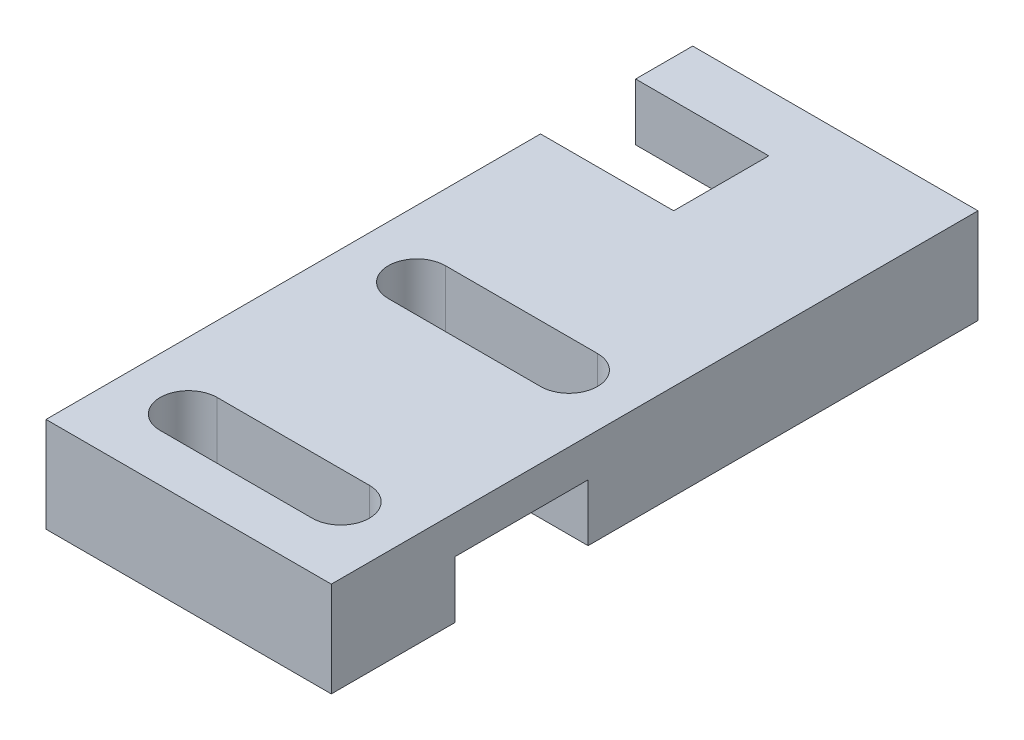
from build123d import *

# Parameters (mm, degrees)
EXTRUDE_1_DEPTH     = 5
SKETCH_2_W          = 7
SKETCH_2_H          = 3
CUT_EXTRUDE_1_DEPTH = 16
SKETCH_3_W          = 3
SKETCH_3_H          = 2
CUT_EXTRUDE_2_DEPTH = 12


with BuildPart() as part:
    # 草图1 → 凸台-拉伸1 (new body)
    with BuildSketch(Plane(origin=(0, 0, 0), x_dir=(1, 0, 0), z_dir=(0, 1, 0))):
        Polygon((15, 34), (0, 34), (0, 31), (7, 31), (7, 26), (0, 26), (0, 0), (15, 0), align=None)
        with BuildLine():
            ThreePointArc((3.5, 2.5), (2, 4), (3.5, 5.5))
            Line((3.5, 5.5), (11.5, 5.5))
            ThreePointArc((11.5, 5.5), (13, 4), (11.5, 2.5))
            Line((11.5, 2.5), (3.5, 2.5))
        make_face(mode=Mode.SUBTRACT)
        with BuildLine():
            ThreePointArc((3.5, 14.5), (2, 16), (3.5, 17.5))
            Line((3.5, 17.5), (11.5, 17.5))
            ThreePointArc((11.5, 17.5), (13, 16), (11.5, 14.5))
            Line((11.5, 14.5), (3.5, 14.5))
        make_face(mode=Mode.SUBTRACT)
    extrude(amount=EXTRUDE_1_DEPTH)

    # 草图2 → 切除-拉伸1 (cut, through all)
    with BuildSketch(Plane.ZY):
        with Locations((-10, 1.5)):
            Rectangle(SKETCH_2_W, SKETCH_2_H)
    extrude(amount=-CUT_EXTRUDE_1_DEPTH, mode=Mode.SUBTRACT)

    # 草图3 → 切除-拉伸2 (cut)
    with BuildSketch(Plane.ZY.offset(-7)):
        with Locations((-32.5, 1)):
            Rectangle(SKETCH_3_W, SKETCH_3_H)
    extrude(amount=CUT_EXTRUDE_2_DEPTH, mode=Mode.SUBTRACT)


solid = part.part
